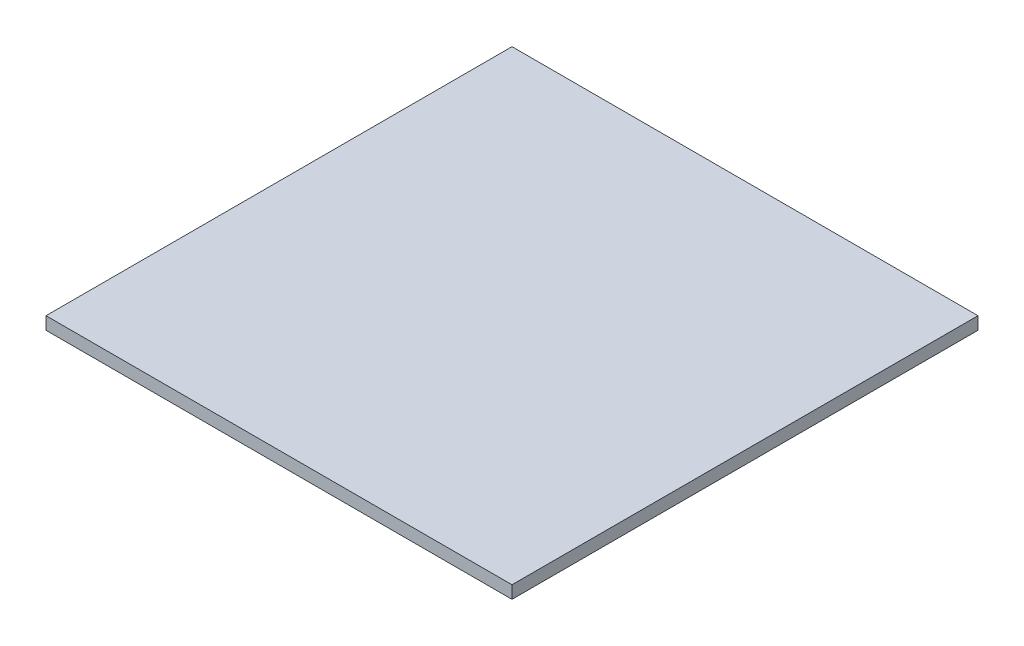
from build123d import *

# Parameters (mm, degrees)
CROQUIS1_W              = 70
CROQUIS1_H              = 70
SALIENTE_EXTRUIR1_DEPTH = 1.9


with BuildPart() as part:
    # Croquis1 → Saliente-Extruir1 (new body)
    with BuildSketch(Plane(origin=(0, 0, 0), x_dir=(1, 0, 0), z_dir=(0, 1, 0))):
        Rectangle(CROQUIS1_W, CROQUIS1_H)
    extrude(amount=SALIENTE_EXTRUIR1_DEPTH)


solid = part.part
